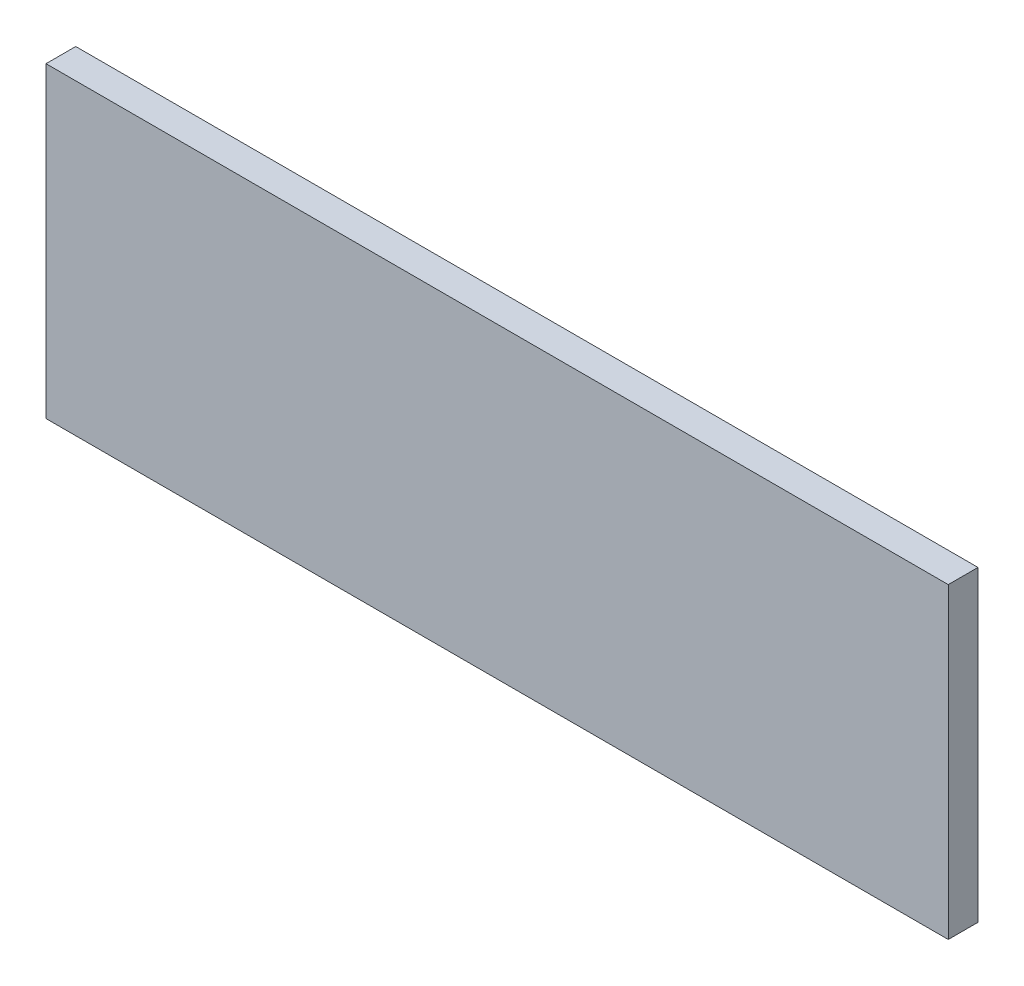
from build123d import *

# Parameters (mm, degrees)
ESQUISSE1_W        = 91
ESQUISSE1_H        = 31
BOSS_EXTRU_1_DEPTH = 3


with BuildPart() as part:
    # Esquisse1 → Boss.-Extru.1 (new body)
    with BuildSketch(Plane.XY):
        Rectangle(ESQUISSE1_W, ESQUISSE1_H)
    extrude(amount=BOSS_EXTRU_1_DEPTH)


solid = part.part
